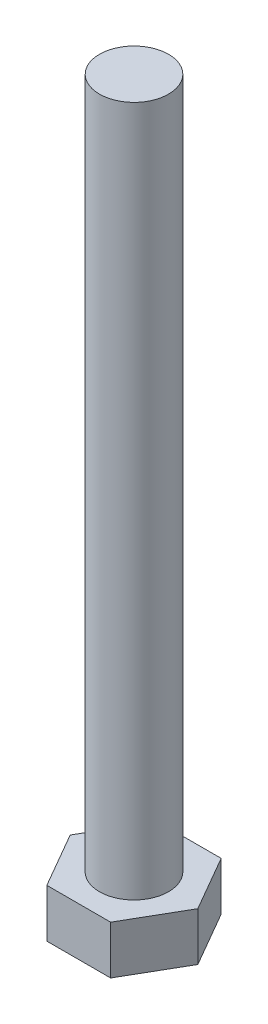
from build123d import *

# Parameters (mm, degrees)
BOSS_EXTRUDE1_DEPTH = 3.5
SKETCH2_R           = 2.5
BOSS_EXTRUDE2_DEPTH = 50


with BuildPart() as part:
    # Sketch1 → Boss-Extrude1 (new body)
    with BuildSketch(Plane(origin=(0, 0, 0), x_dir=(1, 0, 0), z_dir=(0, 1, 0))):
        Polygon((4.618802154, 0), (2.309401077, 4), (-2.309401077, 4), (-4.618802154, 0), (-2.309401077, -4), (2.309401077, -4), align=None)
    extrude(amount=BOSS_EXTRUDE1_DEPTH)

    # Sketch2 → Boss-Extrude2 (add)
    with BuildSketch(Plane(origin=(0, 3.5, 0), x_dir=(1, 0, 0), z_dir=(0, 1, 0))):
        Circle(SKETCH2_R)
    extrude(amount=BOSS_EXTRUDE2_DEPTH)


solid = part.part
